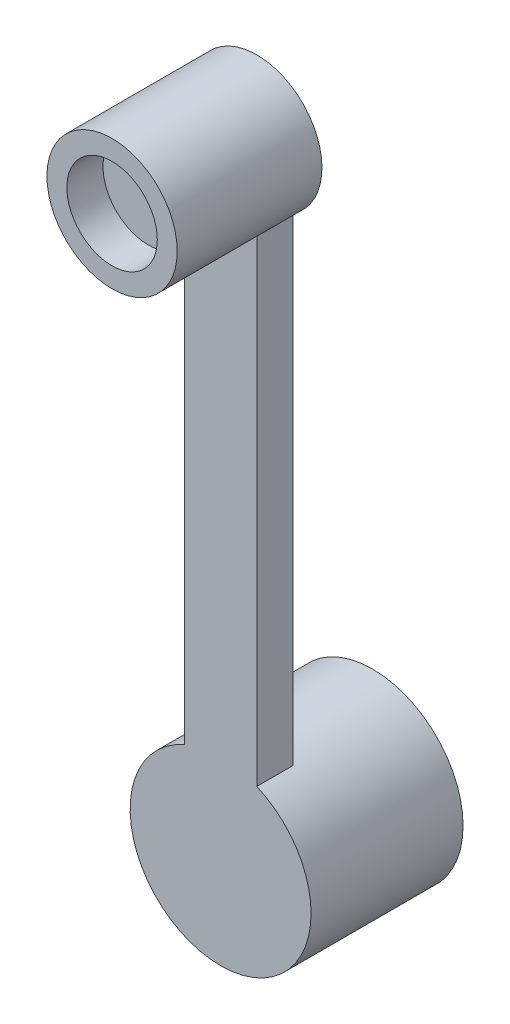
from build123d import *

# Parameters (mm, degrees)
EXTRUDE_1_DEPTH     = 1
SKETCH_2_R          = 1.8
EXTRUDE_2_DEPTH     = 4
SKETCH_3_R          = 1.25
CUT_EXTRUDE_1_DEPTH = 1
SKETCH_4_R          = 2.5
EXTRUDE_3_DEPTH     = 4.2
SKETCH_5_R          = 1.9
CUT_EXTRUDE_2_DEPTH = 4


with BuildPart() as part:
    # 草图1 → 凸台-拉伸1 (new body)
    with BuildSketch(Plane.XY):
        with BuildLine():
            Line((-1, 0), (-1, 17))
            ThreePointArc((-1, 17), (0, 18), (1, 17))
            Line((1, 17), (1, 0))
            ThreePointArc((1, 0), (0, -1), (-1, 0))
        make_face()
    extrude(amount=EXTRUDE_1_DEPTH)

    # 草图2 → 凸台-拉伸2 (add)
    with BuildSketch(Plane.XY):
        with Locations((0, 17)):
            Circle(SKETCH_2_R)
    extrude(amount=EXTRUDE_2_DEPTH)

    # 草图3 → 切除-拉伸1 (cut)
    with BuildSketch(Plane.XY.offset(4)):
        with Locations((0, 17)):
            Circle(SKETCH_3_R)
    extrude(amount=-CUT_EXTRUDE_1_DEPTH, mode=Mode.SUBTRACT)

    # 草图4 → 凸台-拉伸3 (add)
    with BuildSketch(Plane.XY.offset(1)):
        Circle(SKETCH_4_R)
    extrude(amount=-EXTRUDE_3_DEPTH)

    # 草图5 → 切除-拉伸2 (cut)
    with BuildSketch(Plane(origin=(0, 0, -3.2), x_dir=(-1, 0, 0), z_dir=(0, 0, -1))):
        Circle(SKETCH_5_R)
    extrude(amount=-CUT_EXTRUDE_2_DEPTH, mode=Mode.SUBTRACT)


solid = part.part
